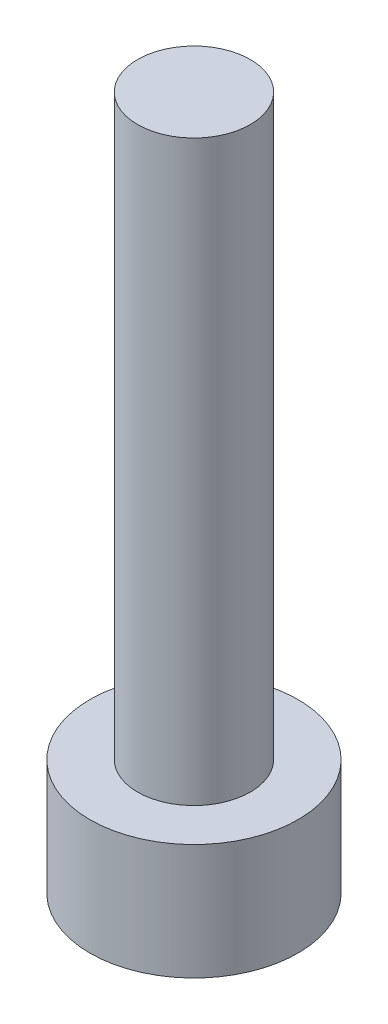
from build123d import *

# Parameters (mm, degrees)
SKETCH1_R           = 3.6
BOSS_EXTRUDE1_DEPTH = 4
SKETCH2_R           = 1.95
BOSS_EXTRUDE2_DEPTH = 20
CUT_EXTRUDE1_DEPTH  = 2


with BuildPart() as part:
    # Sketch1 → Boss-Extrude1 (new body)
    with BuildSketch(Plane(origin=(0, 0, 0), x_dir=(1, 0, 0), z_dir=(0, 1, 0))):
        Circle(SKETCH1_R)
    extrude(amount=BOSS_EXTRUDE1_DEPTH)

    # Sketch2 → Boss-Extrude2 (add)
    with BuildSketch(Plane(origin=(0, 4, 0), x_dir=(1, 0, 0), z_dir=(0, 1, 0))):
        Circle(SKETCH2_R)
    extrude(amount=BOSS_EXTRUDE2_DEPTH)

    # Sketch3 → Cut-Extrude1 (cut)
    with BuildSketch(Plane.XZ):
        Polygon((0, 2.022681568), (-1.751693621, 1.011340784), (-1.751693621, -1.011340784), (0, -2.022681568), (1.751693621, -1.011340784), (1.751693621, 1.011340784), align=None)
    extrude(amount=-CUT_EXTRUDE1_DEPTH, mode=Mode.SUBTRACT)


solid = part.part
